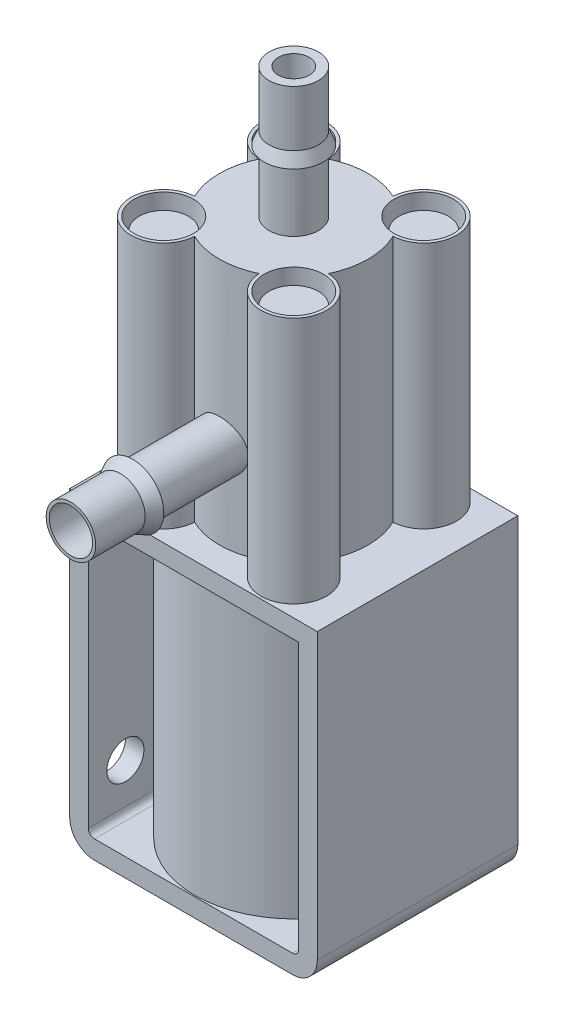
from build123d import *

# Parameters (mm, degrees)
BOSS_EXTRUDE1_DEPTH      = 8.1
BOSS_EXTRUDE1_DEPTH_BACK = 8.1
BOSS_EXTRUDE5_REACH      = 28.793
SKETCH2_R                = 8
SKETCH3_R                = 2.5
BOSS_EXTRUDE6_DEPTH      = 0.5
SKETCH4_R                = 2.4
BOSS_EXTRUDE7_DEPTH      = 20
SKETCH8_R                = 2
BOSS_EXTRUDE8_DEPTH      = 19
SKETCH11_R               = 2
SKETCH11_R_2             = 1.75
BOSS_EXTRUDE10_DEPTH     = 18
CUT_EXTRUDE1_REACH       = 52.725
SKETCH13_R               = 1.5


with BuildPart() as part:
    # Sketch1 → Boss-Extrude1 (new, two sides: drawn at the far end of the back side and taken through both)
    with BuildSketch(Plane.XY.offset(-BOSS_EXTRUDE1_DEPTH_BACK)):
        with BuildLine():
            Line((-10, 12.5), (10, 12.5))
            Line((10, 12.5), (10, -10.5))
            ThreePointArc((10, -10.5), (9.414213562, -11.914213562), (8, -12.5))
            Line((8, -12.5), (-8, -12.5))
            ThreePointArc((-8, -12.5), (-9.414213562, -11.914213562), (-10, -10.5))
            Line((-10, -10.5), (-10, 12.5))
        make_face()
        with BuildLine():
            Line((-8.5, 11), (-8.5, -10.5))
            ThreePointArc((-8.5, -10.5), (-8.353553391, -10.853553391), (-8, -11))
            Line((-8, -11), (8, -11))
            ThreePointArc((8, -11), (8.353553391, -10.853553391), (8.5, -10.5))
            Line((8.5, -10.5), (8.5, 11))
            Line((8.5, 11), (-8.5, 11))
        make_face(mode=Mode.SUBTRACT)
    extrude(amount=BOSS_EXTRUDE1_DEPTH + BOSS_EXTRUDE1_DEPTH_BACK)

    # Sketch2 → Boss-Extrude5 (add, up to next)
    with BuildSketch(Plane(origin=(0, -11, 0), x_dir=(1, 0, 0), z_dir=(0, 1, 0)), mode=Mode.PRIVATE) as boss_extrude5_sk1:
        Circle(SKETCH2_R)
    boss_extrude5_tool1 = extrude(boss_extrude5_sk1.sketch, amount=BOSS_EXTRUDE5_REACH, mode=Mode.PRIVATE) - part.part
    add(boss_extrude5_tool1.solids().sort_by_distance((0, -11, 0))[0])

    # Sketch3 → Boss-Extrude6 (add)
    with BuildSketch(Plane.XZ.offset(12.5)):
        Circle(SKETCH3_R)
    extrude(amount=BOSS_EXTRUDE6_DEPTH)

    # Sketch4 → Boss-Extrude7 (add)
    with BuildSketch(Plane(origin=(0, 12.5, 0), x_dir=(1, 0, 0), z_dir=(0, 1, 0))):
        with BuildLine():
            ThreePointArc((-5.405212541, 2.604549364), (-6, 0), (-5.405212541, -2.604549364))
            ThreePointArc((-5.405212541, -2.604549364), (-7.12383297, -7.12383297), (-2.604549364, -5.405212541))
            ThreePointArc((-2.604549364, -5.405212541), (0, -6), (2.604549364, -5.405212541))
            ThreePointArc((2.604549364, -5.405212541), (7.12383297, -7.12383297), (5.405212541, -2.604549364))
            ThreePointArc((5.405212541, -2.604549364), (6, 0), (5.405212541, 2.604549364))
            ThreePointArc((5.405212541, 2.604549364), (7.12383297, 7.12383297), (2.604549364, 5.405212541))
            ThreePointArc((2.604549364, 5.405212541), (0, 6), (-2.604549364, 5.405212541))
            ThreePointArc((-2.604549364, 5.405212541), (-7.12383297, 7.12383297), (-5.405212541, 2.604549364))
        make_face()
        with Locations((-5.25, 5.25)):
            Circle(SKETCH4_R, mode=Mode.SUBTRACT)
        with Locations((5.25, 5.25)):
            Circle(SKETCH4_R, mode=Mode.SUBTRACT)
        with Locations((5.25, -5.25)):
            Circle(SKETCH4_R, mode=Mode.SUBTRACT)
        with Locations((-5.25, -5.25)):
            Circle(SKETCH4_R, mode=Mode.SUBTRACT)
    extrude(amount=BOSS_EXTRUDE7_DEPTH)

    # Sketch6 → Revolve1 (revolve)
    with BuildSketch(Plane.XY):
        Polygon((1.25, 32.5), (1.25, 43), (2, 43), (2, 38.5), (2.4, 37.5), (2, 37.5), (2, 32.5), align=None)
    revolve(axis=Axis((0, 32.5, 0), (0, 1, 0)))

    # Sketch8 → Boss-Extrude8 (add)
    with BuildSketch(Plane(origin=(0, 12.5, 0), x_dir=(1, 0, 0), z_dir=(0, 1, 0))):
        with Locations((-5.25, 5.25)):
            Circle(SKETCH8_R)
        with Locations((5.25, 5.25)):
            Circle(SKETCH8_R)
        with Locations((5.25, -5.25)):
            Circle(SKETCH8_R)
        with Locations((-5.25, -5.25)):
            Circle(SKETCH8_R)
    extrude(amount=BOSS_EXTRUDE8_DEPTH)

    # Sketch11 → Boss-Extrude10 (add)
    with BuildSketch(Plane.XY):
        with Locations((0, 19.5)):
            Circle(SKETCH11_R)
        with Locations((0, 19.5)):
            Circle(SKETCH11_R_2, mode=Mode.SUBTRACT)
    extrude(amount=BOSS_EXTRUDE10_DEPTH)

    # Sketch12 → Revolve2 (revolve)
    with BuildSketch(Plane(origin=(0, 0, 0), x_dir=(0, 0, -1), z_dir=(1, 0, 0))):
        Polygon((-14, 21.5), (-13, 22), (-13, 21.5), align=None)
    revolve(axis=Axis((0, 19.5, 18), (0, 0, -1)))

    # Sketch13 → Cut-Extrude1 (cut, up to next)
    with BuildSketch(Plane.ZY.offset(10), mode=Mode.PRIVATE) as cut_extrude1_sk1:
        with Locations((-5.1, 7.25)):
            Circle(SKETCH13_R)
    cut_extrude1_tool1 = extrude(cut_extrude1_sk1.sketch, amount=-CUT_EXTRUDE1_REACH, mode=Mode.PRIVATE) & part.part
    # Sketch13 → Cut-Extrude1 (cut, up to next)
    with BuildSketch(Plane.ZY.offset(10), mode=Mode.PRIVATE) as cut_extrude1_sk2:
        with Locations((5.1, -7.25)):
            Circle(SKETCH13_R)
    cut_extrude1_tool2 = extrude(cut_extrude1_sk2.sketch, amount=-CUT_EXTRUDE1_REACH, mode=Mode.PRIVATE) & part.part
    add(cut_extrude1_tool1.solids().sort_by_distance((-10, 7.25, -5.1))[0], mode=Mode.SUBTRACT)
    add(cut_extrude1_tool2.solids().sort_by_distance((-10, -7.25, 5.1))[0], mode=Mode.SUBTRACT)


solid = part.part
